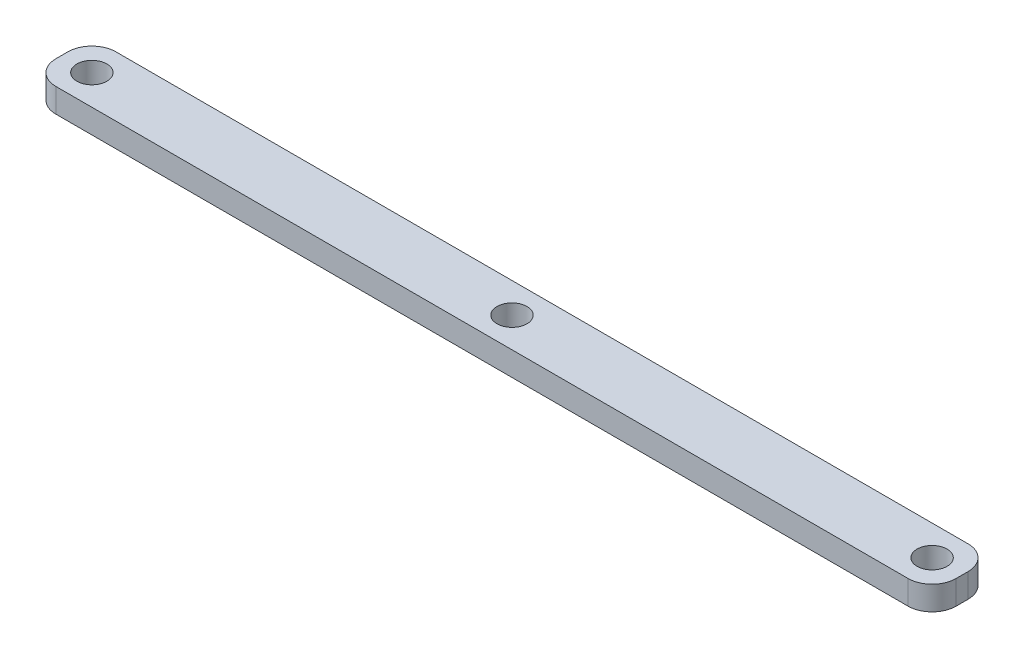
from build123d import *

# Parameters (mm, degrees)
CROQUIS1_W              = 150
CROQUIS1_H              = 10
CROQUIS1_R              = 2.5
SALIENTE_EXTRUIR1_DEPTH = 4
REDONDEO1_R             = 4


with BuildPart() as part:
    # Croquis1 → Saliente-Extruir1 (new body)
    with BuildSketch(Plane(origin=(0, 0, 0), x_dir=(1, 0, 0), z_dir=(0, 1, 0))):
        Rectangle(CROQUIS1_W, CROQUIS1_H)
        with Locations((-70, 0)):
            Circle(CROQUIS1_R, mode=Mode.SUBTRACT)
        with Locations((70, 0)):
            Circle(CROQUIS1_R, mode=Mode.SUBTRACT)
        Circle(CROQUIS1_R, mode=Mode.SUBTRACT)
    extrude(amount=SALIENTE_EXTRUIR1_DEPTH)

    # Redondeo1
    redondeo1_edges = [part.edges().sort_by_distance(p)[0] for p in [
        (75, 2, 5),
        (-75, 2, 5),
        (-75, 2, -5),
        (75, 2, -5),
    ]]
    fillet(redondeo1_edges, radius=REDONDEO1_R)


solid = part.part
